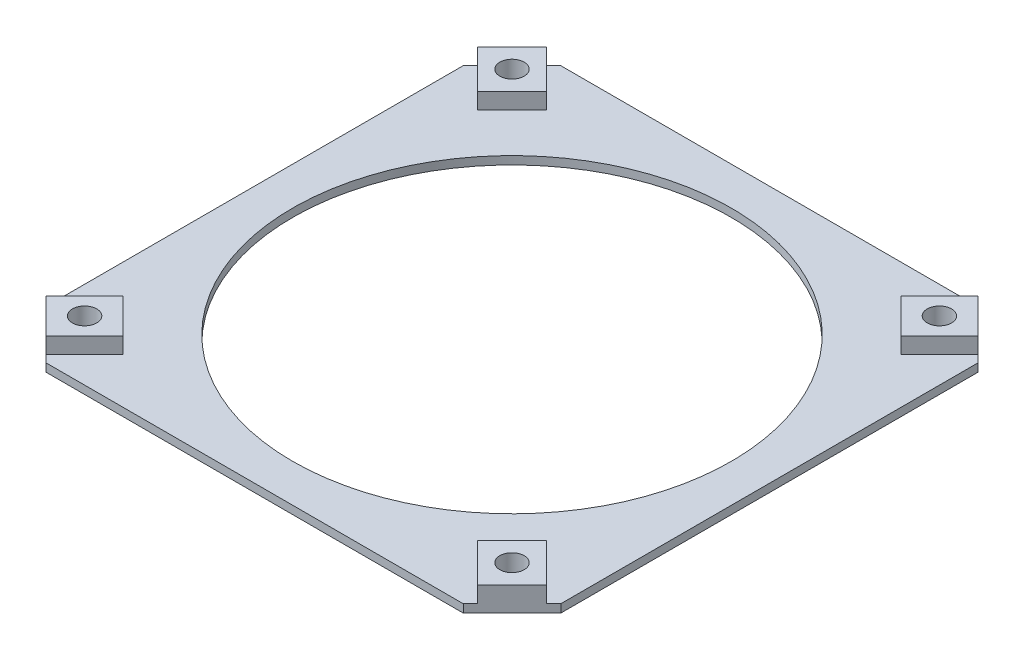
from build123d import *

# Parameters (mm, degrees)
SKETCH1_R           = 27
BOSS_EXTRUDE1_DEPTH = 1
BOSS_EXTRUDE3_DEPTH = 2
SKETCH14_R          = 1.5
CUT_EXTRUDE2_DEPTH  = 4
CIRPATTERN2_COUNT   = 4


with BuildPart() as part:
    # Sketch1 → Boss-Extrude1 (new body)
    with BuildSketch(Plane(origin=(0, 0, 0), x_dir=(1, 0, 0), z_dir=(0, 1, 0))):
        Polygon((-31.68, 25.676767512), (-25.68, 31.676767512), (25.68, 31.676767512), (31.68, 25.676767512), (31.68, -25.676767512), (25.68, -31.676767512), (-25.68, -31.676767512), (-31.68, -25.676767512), align=None)
        Circle(SKETCH1_R, mode=Mode.SUBTRACT)
    extrude(amount=BOSS_EXTRUDE1_DEPTH)

    # Sketch2 → Boss-Extrude3 (add)
    with BuildSketch(Plane(origin=(0, 1, 0), x_dir=(1, 0, 0), z_dir=(0, 1, 0))):
        Polygon((26.557063412, 30.799704099), (21.809040421, 26.051681108), (26.051681108, 21.809040421), (30.799704099, 26.557063412), align=None)
        Polygon((30.799704099, -26.557063412), (26.051681108, -21.809040421), (21.809040421, -26.051681108), (26.557063412, -30.799704099), align=None)
        Polygon((-26.557063412, -30.799704099), (-21.809040421, -26.051681108), (-26.051681108, -21.809040421), (-30.799704099, -26.557063412), align=None)
        Polygon((-30.799704099, 26.557063412), (-26.051681108, 21.809040421), (-21.809040421, 26.051681108), (-26.557063412, 30.799704099), align=None)
    extrude(amount=BOSS_EXTRUDE3_DEPTH)

    # Sketch14 → Cut-Extrude2 (cut, through all)
    with BuildSketch(Plane(origin=(0, 3, 0), x_dir=(1, 0, 0), z_dir=(0, 1, 0))):
        with Locations((26.30437226, 26.30437226)):
            Circle(SKETCH14_R)
    cut_extrude2 = extrude(amount=-CUT_EXTRUDE2_DEPTH, mode=Mode.SUBTRACT)

    # CirPattern2: Cut-Extrude2 ×4 about axis
    cirpattern2_axis = Axis((0, 0, 0), (0, 1, 0))
    for i in range(1, CIRPATTERN2_COUNT):
        add(cut_extrude2.rotate(cirpattern2_axis, i * 360 / CIRPATTERN2_COUNT), mode=Mode.SUBTRACT)


solid = part.part
